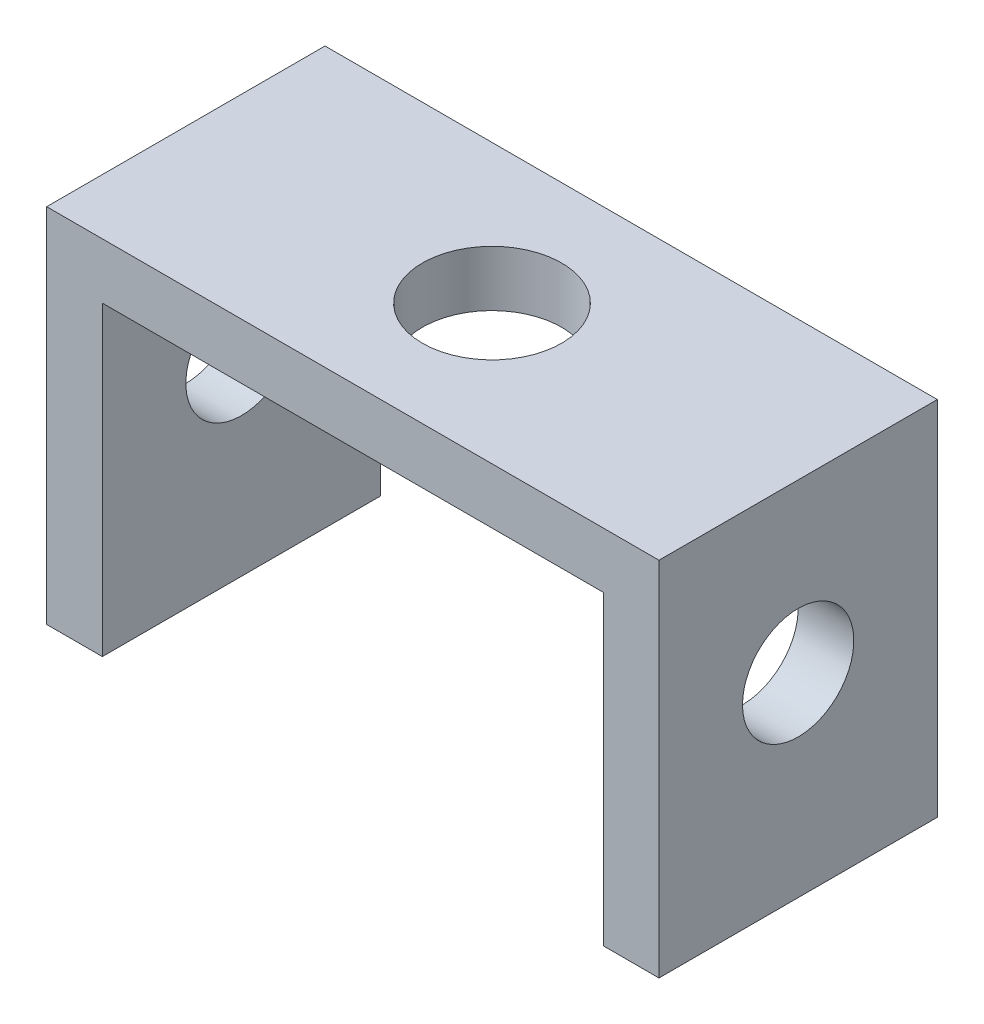
from build123d import *

# Parameters (mm, degrees)
SKETCH1_W           = 110
SKETCH1_H           = 50
SKETCH1_R           = 12.5
BOSS_EXTRUDE1_DEPTH = 10
BOSS_EXTRUDE2_START = 55
SKETCH2_W           = 50
SKETCH2_H           = 65
SKETCH2_R           = 10
BOSS_EXTRUDE2_DEPTH = 10
BOSS_EXTRUDE3_START = -55
SKETCH2_2_W         = 50
SKETCH2_2_H         = 65
SKETCH2_2_R         = 10
BOSS_EXTRUDE3_DEPTH = 10


with BuildPart() as part:
    # Sketch1 → Boss-Extrude1 (new body)
    with BuildSketch(Plane(origin=(0, 0, 0), x_dir=(1, 0, 0), z_dir=(0, 1, 0))):
        Rectangle(SKETCH1_W, SKETCH1_H)
        Circle(SKETCH1_R, mode=Mode.SUBTRACT)
    extrude(amount=BOSS_EXTRUDE1_DEPTH)

    # Sketch2 → Boss-Extrude2 (add)
    with BuildSketch(Plane(origin=(0, 0, 0), x_dir=(0, 0, -1), z_dir=(1, 0, 0)).offset(BOSS_EXTRUDE2_START)):
        with Locations((0, -22.5)):
            Rectangle(SKETCH2_W, SKETCH2_H)
        with Locations((0, -20)):
            Circle(SKETCH2_R, mode=Mode.SUBTRACT)
    extrude(amount=-BOSS_EXTRUDE2_DEPTH)

    # Sketch2_2 → Boss-Extrude3 (add)
    with BuildSketch(Plane(origin=(0, 0, 0), x_dir=(0, 0, -1), z_dir=(1, 0, 0)).offset(BOSS_EXTRUDE3_START)):
        with Locations((0, -22.5)):
            Rectangle(SKETCH2_2_W, SKETCH2_2_H)
        with Locations((0, -20)):
            Circle(SKETCH2_2_R, mode=Mode.SUBTRACT)
    extrude(amount=BOSS_EXTRUDE3_DEPTH)


solid = part.part
